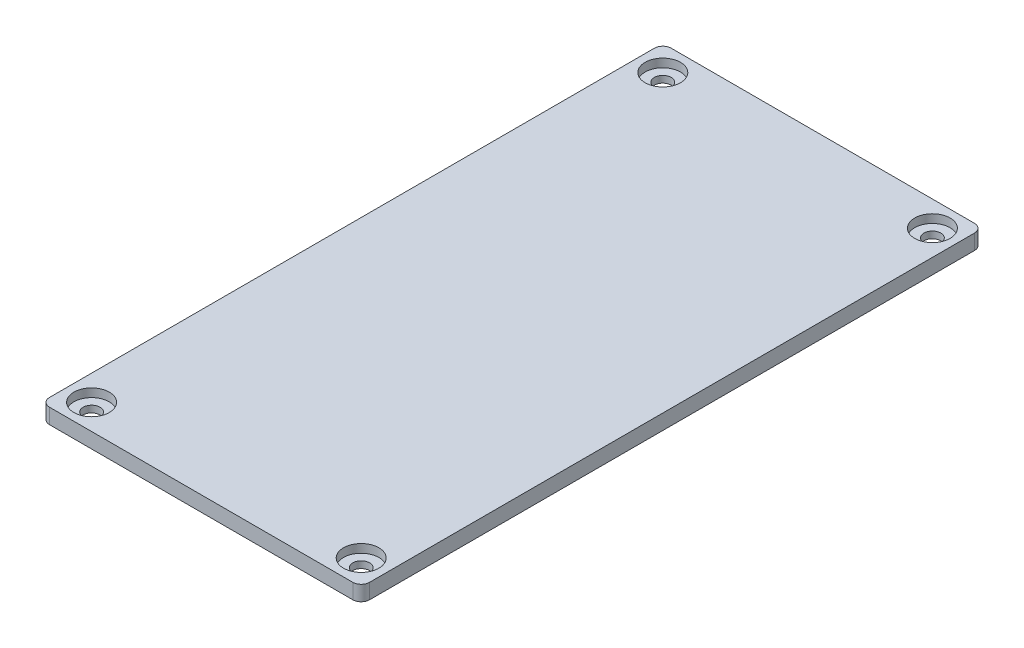
from build123d import *

# Parameters (mm, degrees)
SKETCH1_W           = 38
SKETCH1_H           = 73.8
BOSS_EXTRUDE1_DEPTH = 1.8
SKETCH2_R           = 1
CUT_EXTRUDE1_DEPTH  = 42.543350852
SKETCH3_R           = 2.1
CUT_EXTRUDE2_DEPTH  = 1
FILLET1_R           = 1


with BuildPart() as part:
    # Sketch1 → Boss-Extrude1 (new body)
    with BuildSketch(Plane(origin=(0, 0, 0), x_dir=(1, 0, 0), z_dir=(0, 1, 0))):
        Rectangle(SKETCH1_W, SKETCH1_H)
    extrude(amount=BOSS_EXTRUDE1_DEPTH)

    # Sketch2 → Cut-Extrude1 (cut, through all)
    with BuildSketch(Plane(origin=(0, 1.8, 0), x_dir=(1, 0, 0), z_dir=(0, 1, 0))):
        with Locations((-16, 33.9)):
            Circle(SKETCH2_R)
        with Locations((16, 33.9)):
            Circle(SKETCH2_R)
    cut_extrude1 = extrude(amount=-CUT_EXTRUDE1_DEPTH, mode=Mode.SUBTRACT)

    # Sketch3 → Cut-Extrude2 (cut)
    with BuildSketch(Plane(origin=(0, 1.8, 0), x_dir=(1, 0, 0), z_dir=(0, 1, 0))):
        with Locations((-16, 33.9)):
            Circle(SKETCH3_R)
        with Locations((16, 33.9)):
            Circle(SKETCH3_R)
    cut_extrude2 = extrude(amount=-CUT_EXTRUDE2_DEPTH, mode=Mode.SUBTRACT)

    # Mirror1: Cut-Extrude1, Cut-Extrude2 across plane
    add(cut_extrude1.mirror(Plane.XY), mode=Mode.SUBTRACT)
    add(cut_extrude2.mirror(Plane.XY), mode=Mode.SUBTRACT)

    # Fillet1
    fillet1_edges = [part.edges().sort_by_distance(p)[0] for p in [
        (-19, 0.9, -36.9),
        (19, 0.9, -36.9),
        (19, 0.9, 36.9),
        (-19, 0.9, 36.9),
    ]]
    fillet(fillet1_edges, radius=FILLET1_R)


solid = part.part
